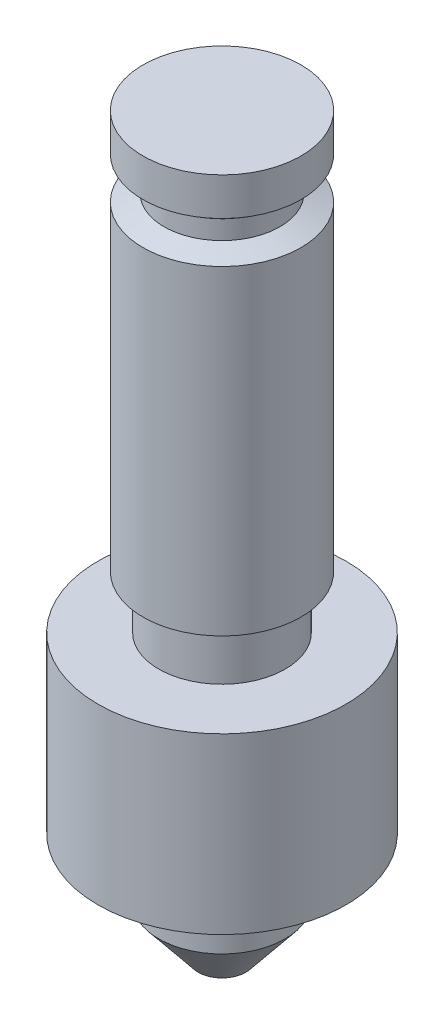
from build123d import *


with BuildPart() as part:
    # Sketch1 → Revolve1 (revolve)
    with BuildSketch(Plane.XY):
        Polygon((0, 0), (-7.9629, 0), (-7.9629, -3.81), (-5.842, -5.334), (-5.842, -7.239), (-7.9629, -8.001), (-7.9629, -40.259), (-6.3754, -40.259), (-6.3754, -45.593), (-12.5, -45.593), (-12.5, -63.119), (-6.3754, -63.119), (-6.3754, -69.142247751), (-2.410616984, -74.041), (0, -74.041), align=None)
    revolve(axis=Axis((0, 0, 0), (0, 1, 0)))


solid = part.part
